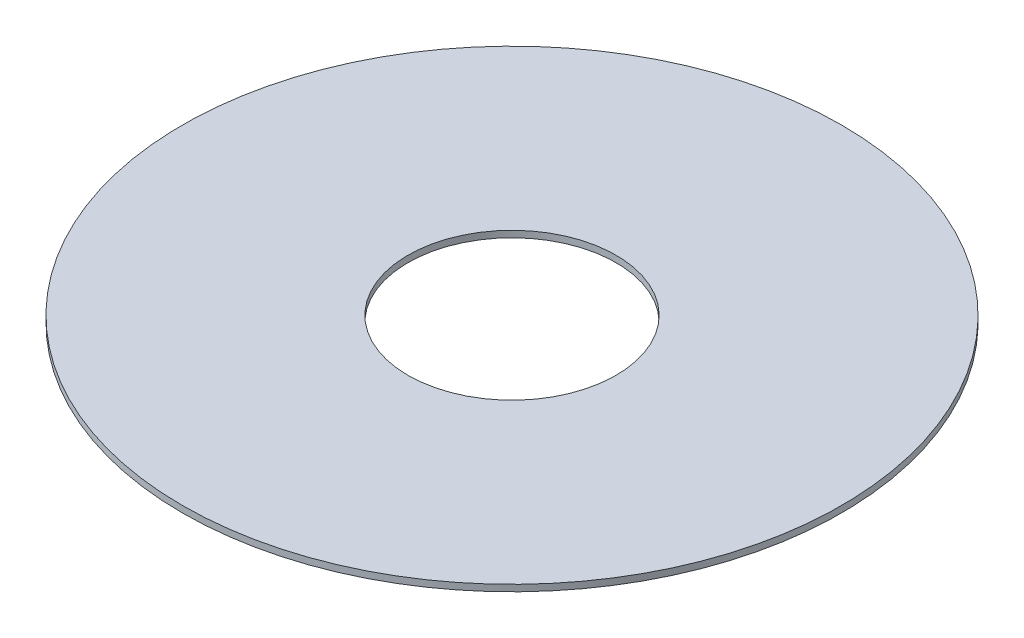
from build123d import *

# Parameters (mm, degrees)
SKETCH1_R           = 241.3
SKETCH1_R_2         = 76.2
BOSS_EXTRUDE1_DEPTH = 4.7625


with BuildPart() as part:
    # Sketch1 → Boss-Extrude1 (new body)
    with BuildSketch(Plane(origin=(0, 0, 0), x_dir=(1, 0, 0), z_dir=(0, 1, 0))):
        Circle(SKETCH1_R)
        Circle(SKETCH1_R_2, mode=Mode.SUBTRACT)
    extrude(amount=BOSS_EXTRUDE1_DEPTH)


solid = part.part
